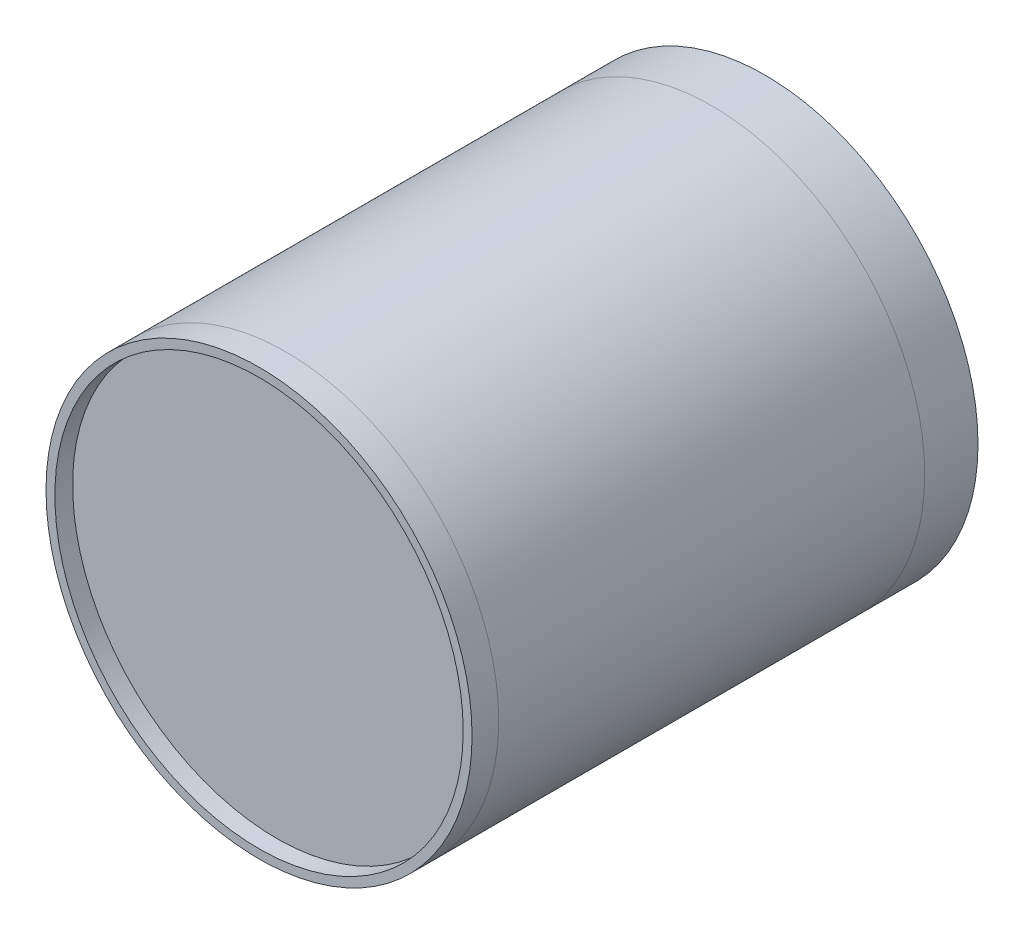
from build123d import *

# Parameters (mm, degrees)
SKETCH1_R           = 609.6
BOSS_EXTRUDE1_DEPTH = 152.4
SKETCH5_R           = 25.4
SKETCH5_R_2         = 76.2
BOSS_EXTRUDE5_DEPTH = 25.4
SKETCH5_3_R         = 25.4
BOSS_EXTRUDE6_DEPTH = 50.8
SKETCH2_R           = 609.6
SKETCH2_R_2         = 603.25
BOSS_EXTRUDE2_DEPTH = 1219.2
SKETCH3_R           = 609.6
BOSS_EXTRUDE3_DEPTH = 76.2
SKETCH4_R           = 584.2
CUT_EXTRUDE1_DEPTH  = 50.8


with BuildPart() as part:
    # Sketch1 → Boss-Extrude1 (new body)
    with BuildSketch(Plane.XY):
        Circle(SKETCH1_R)
    extrude(amount=-BOSS_EXTRUDE1_DEPTH)

    # Sketch5 → Boss-Extrude5 (add)
    with BuildSketch(Plane.XY):
        Circle(SKETCH5_R)
        Circle(SKETCH5_R_2)
        Circle(SKETCH5_R, mode=Mode.SUBTRACT)
    extrude(amount=BOSS_EXTRUDE5_DEPTH)

    # Sketch5_3 → Boss-Extrude6 (add)
    with BuildSketch(Plane.XY):
        Circle(SKETCH5_3_R)
    extrude(amount=BOSS_EXTRUDE6_DEPTH)


with BuildPart() as body_2:
    # Sketch2 → Boss-Extrude2 (new body)
    with BuildSketch(Plane.XY):
        Circle(SKETCH2_R)
        Circle(SKETCH2_R_2, mode=Mode.SUBTRACT)
    extrude(amount=BOSS_EXTRUDE2_DEPTH)


with BuildPart() as body_3:
    # Sketch3 → Boss-Extrude3 (new body)
    with BuildSketch(Plane.XY.offset(1219.2)):
        Circle(SKETCH3_R)
    extrude(amount=BOSS_EXTRUDE3_DEPTH)

    # Sketch4 → Cut-Extrude1 (cut)
    with BuildSketch(Plane.XY.offset(1295.4)):
        Circle(SKETCH4_R)
    extrude(amount=-CUT_EXTRUDE1_DEPTH, mode=Mode.SUBTRACT)


solid = Compound([part.part, body_2.part, body_3.part])
